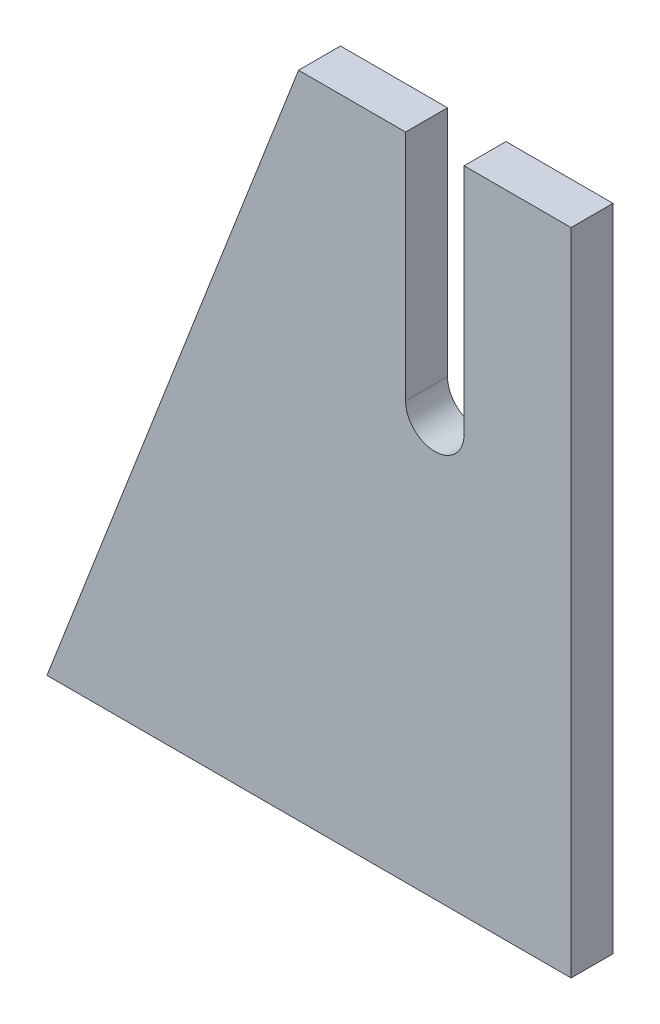
from build123d import *

# Parameters (mm, degrees)
BOSS_EXTRU_1_DEPTH = 4


with BuildPart() as part:
    # Esquisse1 → Boss.-Extru.1 (new body)
    with BuildSketch(Plane.XY):
        with BuildLine():
            Line((0, 0), (-50, 0))
            Line((-50, 0), (-26, 62))
            Line((-26, 62), (-15.79, 62))
            Line((-15.79, 62), (-15.79, 39.79))
            ThreePointArc((-15.79, 39.79), (-13, 37), (-10.21, 39.79))
            Line((-10.21, 39.79), (-10.21, 62))
            Line((-10.21, 62), (0, 62))
            Line((0, 62), (0, 0))
        make_face()
    extrude(amount=BOSS_EXTRU_1_DEPTH)


solid = part.part
